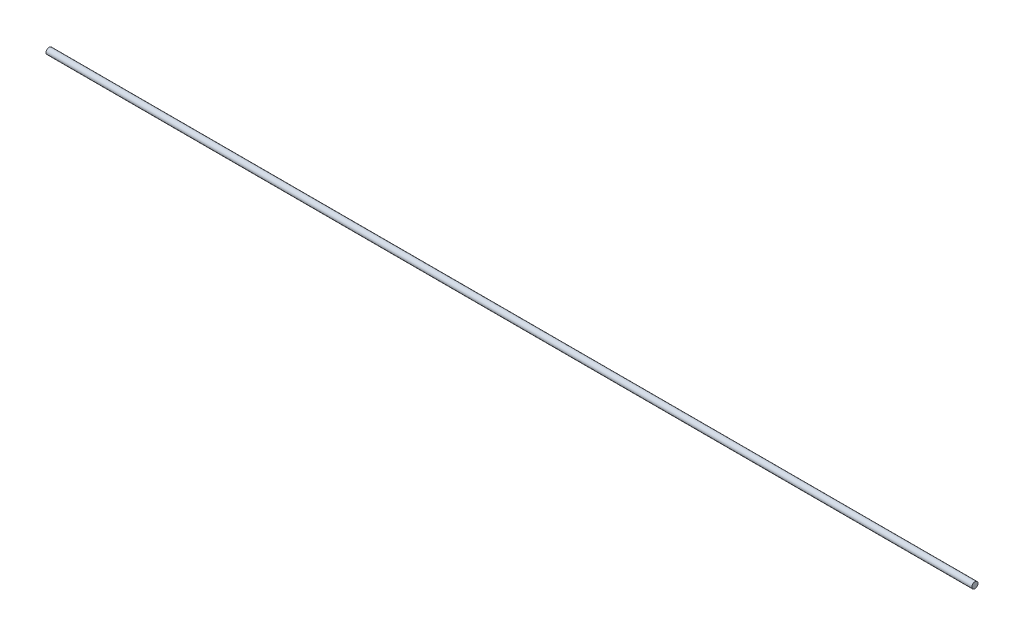
from build123d import *

# Parameters (mm, degrees)
SKETCH1_R           = 0.06
BOSS_EXTRUDE1_DEPTH = 18


with BuildPart() as part:
    # Sketch1 → Boss-Extrude1 (new body)
    with BuildSketch(Plane(origin=(0, 0, 0), x_dir=(0, 0, -1), z_dir=(1, 0, 0))):
        Circle(SKETCH1_R)
    extrude(amount=BOSS_EXTRUDE1_DEPTH)


solid = part.part
